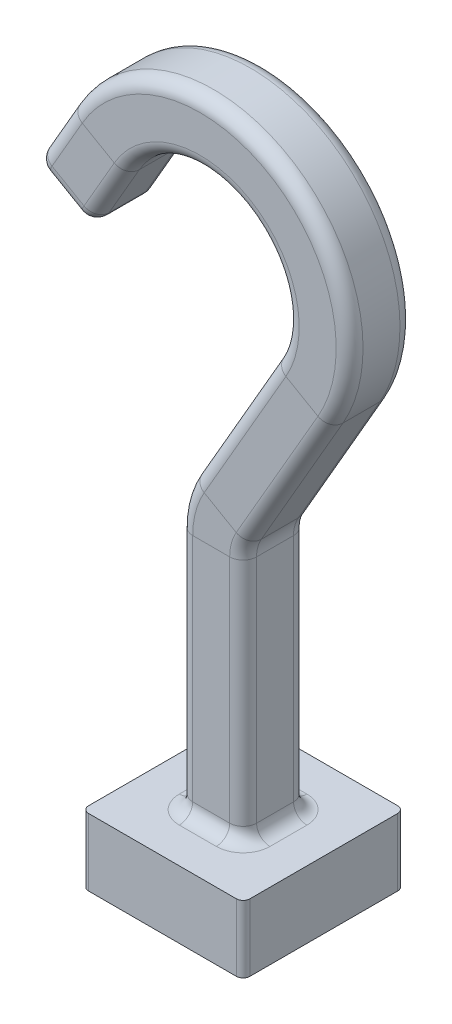
from build123d import *

# Parameters (mm, degrees)
SKETCH1_W           = 24
SKETCH1_H           = 24
BOSS_EXTRUDE1_DEPTH = 10
FILLET1_R           = 2
FILLET2_R           = 1


with BuildPart() as part:
    # Sketch1 → Boss-Extrude1 (new body)
    with BuildSketch(Plane(origin=(0, 0, 0), x_dir=(1, 0, 0), z_dir=(0, 1, 0))):
        Rectangle(SKETCH1_W, SKETCH1_H)
    extrude(amount=BOSS_EXTRUDE1_DEPTH)

    # Sweep1: sweep along a path in Sketch2
    with BuildLine(Plane.XY) as sweep1_path:
        Line((0, 10), (0, 46.32050807568873))
        ThreePointArc((0, 46.32050807568873), (0.3407417371093189, 48.90869852671398), (1.3397459621556382, 51.320508075688814))
        Line((1.3397459621556382, 51.320508075688814), (13.500000000000028, 72.38268590217983))
        ThreePointArc((13.500000000000028, 72.38268590217983), (7.094555433772385, 96.28813046840753), (-16.810889132455312, 89.88268590217987))
        Line((-16.810889132455312, 89.88268590217987), (-22.310889132455326, 80.35640646055106))
    # Sketch3 → Sweep1 (sweep)
    with BuildSketch(Plane(origin=(0, 10, 0), x_dir=(1, 0, 0), z_dir=(0, 1, 0))):
        with BuildLine():
            Line((2.7499999999999853, -4.750000000000002), (-2.749999999999986, -4.750000000000001))
            ThreePointArc((-2.749999999999986, -4.750000000000001), (-4.164213562373095, -4.164213562373096), (-4.75, -2.7499999999999867))
            Line((-4.75, -2.7499999999999867), (-4.75, 2.7499999999999853))
            ThreePointArc((-4.75, 2.7499999999999853), (-4.164213562373094, 4.164213562373095), (-2.7499999999999853, 4.749999999999999))
            Line((-2.7499999999999853, 4.749999999999999), (2.7499999999999862, 4.749999999999998))
            ThreePointArc((2.7499999999999862, 4.749999999999998), (4.164213562373096, 4.164213562373094), (4.750000000000001, 2.749999999999984))
            Line((4.750000000000001, 2.749999999999984), (4.75, -2.749999999999987))
            ThreePointArc((4.75, -2.749999999999987), (4.164213562373096, -4.164213562373097), (2.7499999999999853, -4.750000000000002))
        make_face()
    sweep(path=sweep1_path.line)

    # Fillet1
    fillet1_edges = [part.edges().sort_by_distance(p)[0] for p in [
        (-18.704574400656547, 78.27429967936449, 4.164213562373096),
        (-22.310889132455365, 80.35640646055109, 4.750000000000002),
        (-25.91720386425412, 82.43851324173762, 4.164213562373098),
        (-26.42450980043141, 82.73140646055109, 1.78e-15),
        (-25.917203864254123, 82.43851324173762, -4.164213562373092),
        (-22.310889132455365, 80.35640646055109, -4.749999999999998),
        (-18.704574400656547, 78.27429967936449, -4.164213562373094),
        (-18.197268464479265, 77.98140646055103, 8.9e-16),
        (-4.4e-16, 10, 4.750000000000002),
        (4.164213562373095, 10, 4.164213562373098),
        (4.75, 10, 1.78e-15),
        (4.164213562373097, 10, -4.164213562373092),
        (4.4e-16, 10, -4.749999999999998),
        (-4.164213562373095, 10, -4.164213562373094),
        (-4.75, 10, 8.9e-16),
        (-4.164213562373096, 10, 4.164213562373096),
    ]]
    fillet(fillet1_edges, radius=FILLET1_R)

    # Fillet2
    fillet2_edges = [part.edges().sort_by_distance(p)[0] for p in [
        (12, 5, 12),
        (-12, 5, 12),
        (-12, 5, -12),
        (12, 5, -12),
    ]]
    fillet(fillet2_edges, radius=FILLET2_R)


solid = part.part
